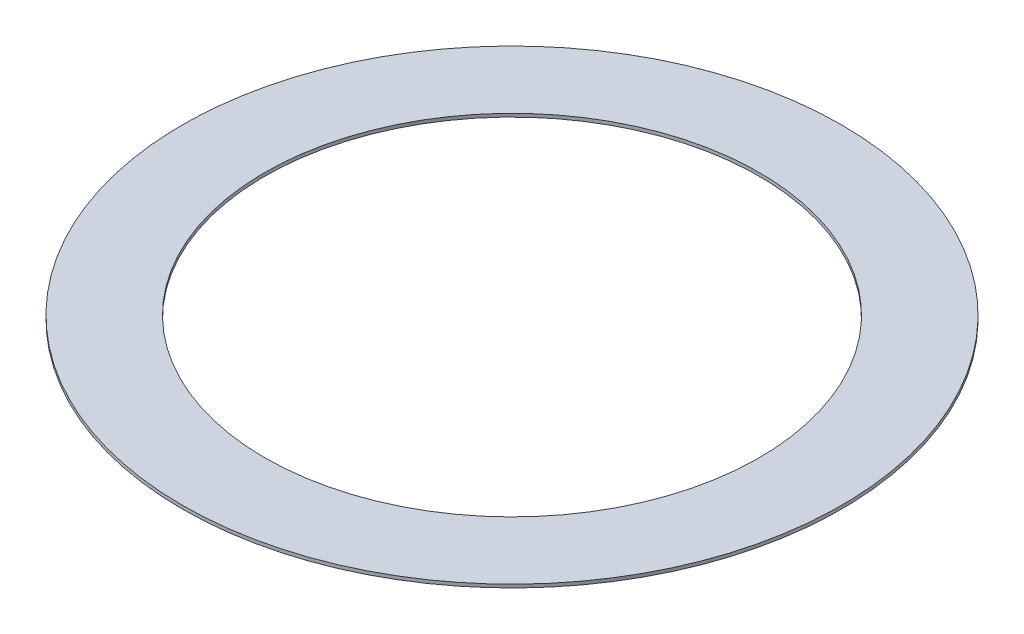
from build123d import *

# Parameters (mm, degrees)
SKETCH2_W = 3.175
SKETCH2_H = 0.127


with BuildPart() as part:
    # Sketch2 → Revolve1 (revolve)
    with BuildSketch(Plane(origin=(0, 0, 0), x_dir=(1, 0, 0), z_dir=(0, 0, -1))):
        with Locations((-11.1125, 0.0635)):
            Rectangle(SKETCH2_W, SKETCH2_H)
    revolve(axis=Axis((0, 55, 0), (0, -1, 0)))


solid = part.part
